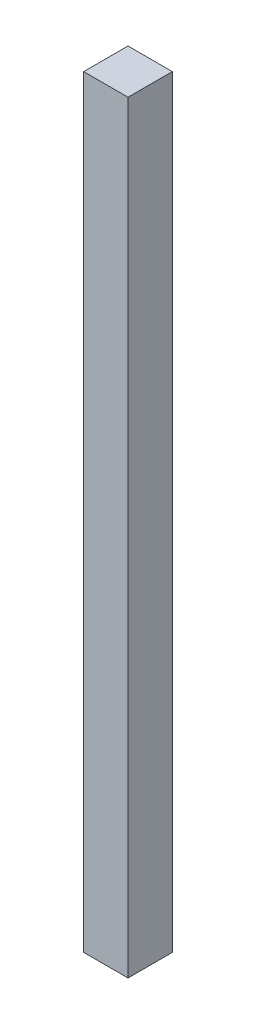
from build123d import *

# Parameters (mm, degrees)
SKETCH1_W           = 15
SKETCH1_H           = 15
BOSS_EXTRUDE1_DEPTH = 258


with BuildPart() as part:
    # Sketch1 → Boss-Extrude1 (new body)
    with BuildSketch(Plane(origin=(0, 0, 0), x_dir=(1, 0, 0), z_dir=(0, 1, 0))):
        Rectangle(SKETCH1_W, SKETCH1_H)
    extrude(amount=BOSS_EXTRUDE1_DEPTH)


solid = part.part
